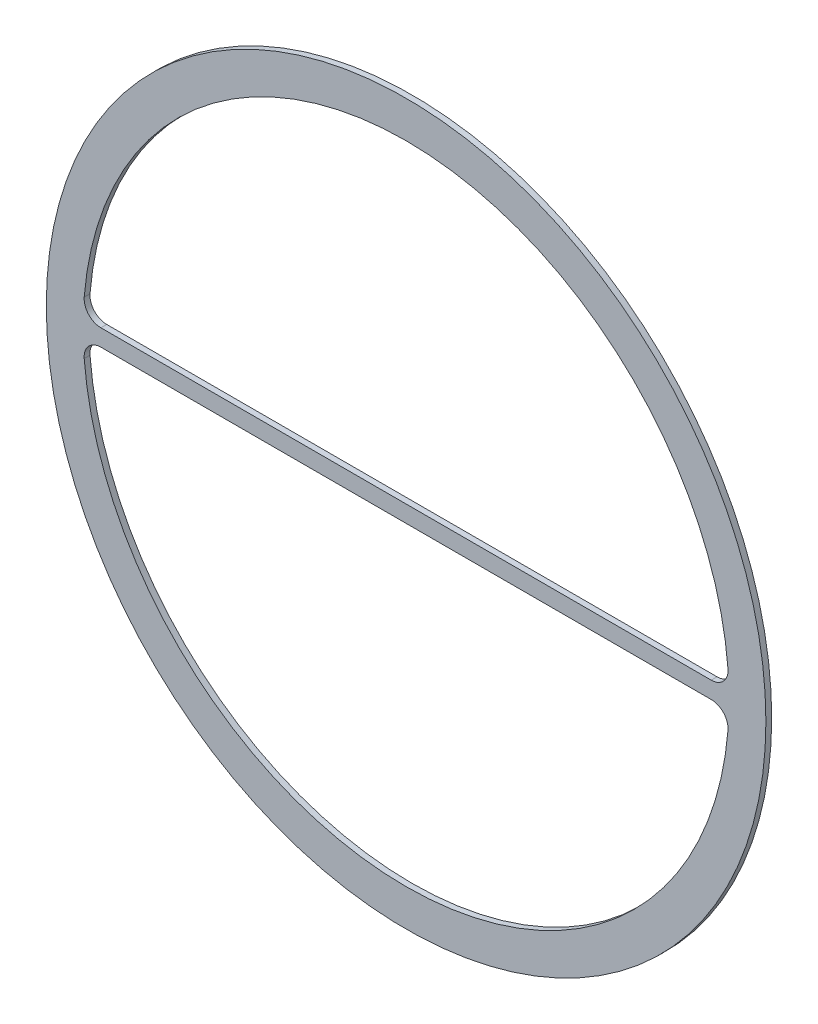
from build123d import *

# Parameters (mm, degrees)
SKETCH1_R           = 278.5
BOSS_EXTRUDE1_DEPTH = 2.25
FILLET1_R           = 13


with BuildPart() as part:
    # Sketch1 → Boss-Extrude1 (new body, symmetric)
    with BuildSketch(Plane.XY):
        Circle(SKETCH1_R)
        with BuildLine():
            Line((249.915485715, -6.5), (-249.915485715, -6.5))
            ThreePointArc((-249.915485715, -6.5), (0, -250), (249.915485715, -6.5))
        make_face(mode=Mode.SUBTRACT)
        with BuildLine():
            Line((249.915485715, 6.5), (-249.915485715, 6.5))
            ThreePointArc((-249.915485715, 6.5), (0, 250), (249.915485715, 6.5))
        make_face(mode=Mode.SUBTRACT)
    extrude(amount=BOSS_EXTRUDE1_DEPTH, both=True)

    # Fillet1
    fillet1_edges = [part.edges().sort_by_distance(p)[0] for p in [
        (-249.915485715, -6.5, 0),
        (249.915485715, -6.5, 0),
        (249.915485715, 6.5, 0),
        (-249.915485715, 6.5, 0),
    ]]
    fillet(fillet1_edges, radius=FILLET1_R)


solid = part.part
